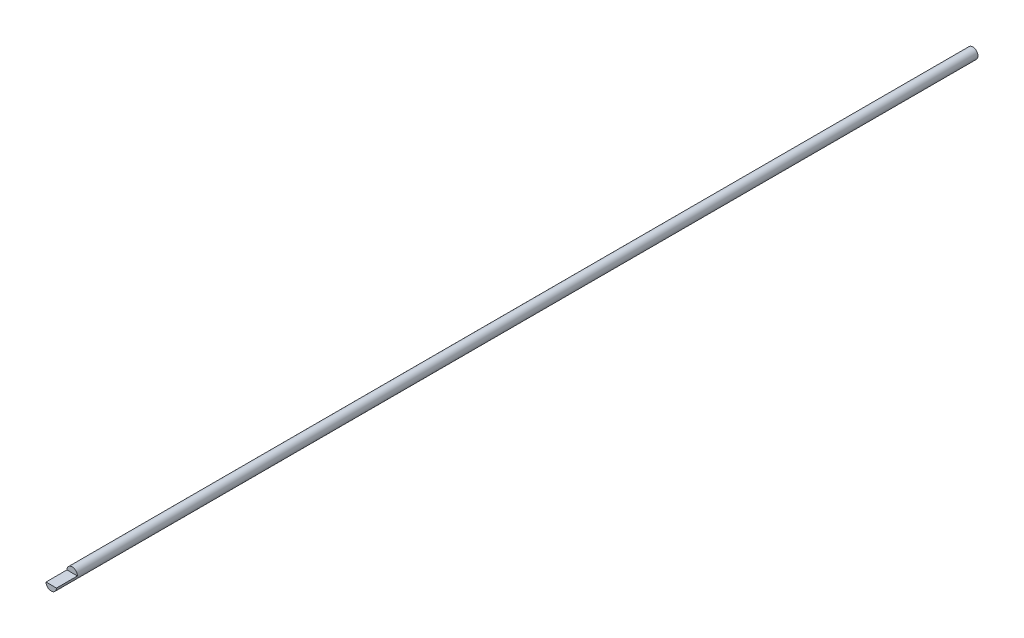
from build123d import *

# Parameters (mm, degrees)
SKETCH1_R           = 3.175
BOSS_EXTRUDE1_DEPTH = 558.8
CUT_EXTRUDE1_DEPTH  = 12.7


with BuildPart() as part:
    # Sketch1 → Boss-Extrude1 (new body)
    with BuildSketch(Plane.XY):
        Circle(SKETCH1_R)
    extrude(amount=BOSS_EXTRUDE1_DEPTH)

    # Sketch3 → Cut-Extrude1 (cut)
    with BuildSketch(Plane.XY.offset(558.8)):
        with BuildLine():
            Line((-3.175, 0), (3.175, 0))
            ThreePointArc((3.175, 0), (0, 3.175), (-3.175, 0))
        make_face()
    extrude(amount=-CUT_EXTRUDE1_DEPTH, mode=Mode.SUBTRACT)


solid = part.part
